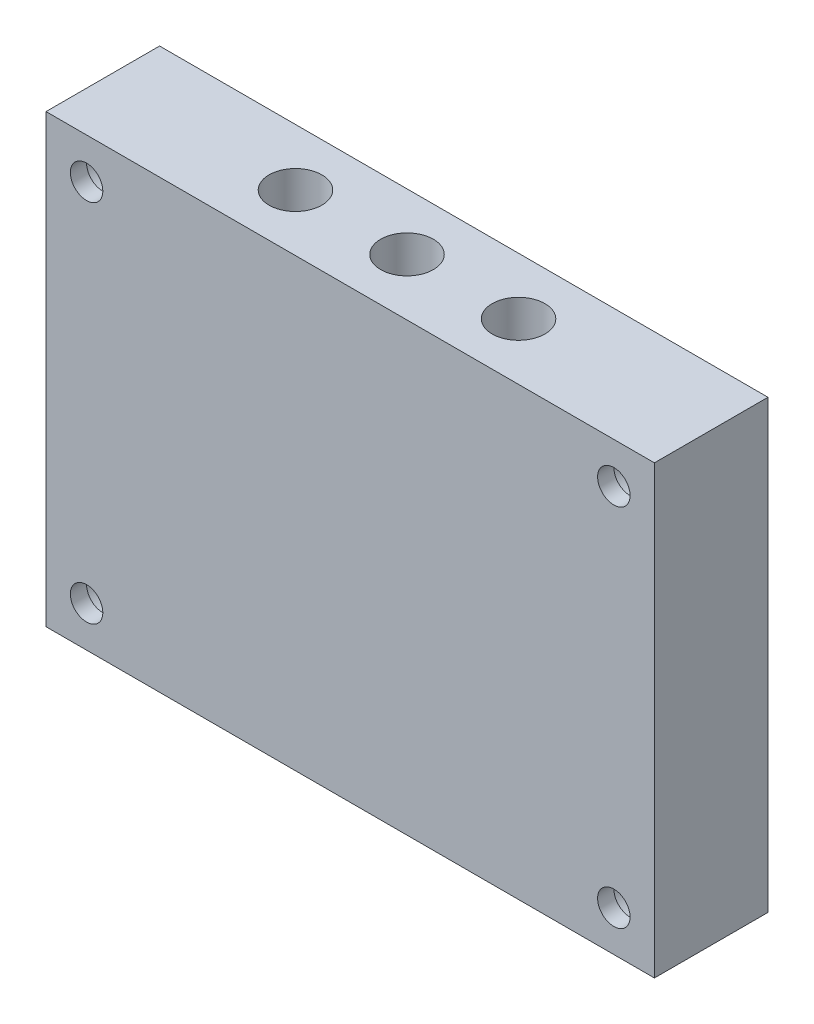
from build123d import *

# Parameters (mm, degrees)
SKETCH2_W               = 75
SKETCH2_H               = 55
SKETCH2_W_2             = 55
SKETCH2_H_2             = 35
BOSS_EXTRUDE1_DEPTH     = 12
SKETCH3_W               = 75
SKETCH3_H               = 55
BOSS_EXTRUDE2_DEPTH     = 2
SKETCH5_R               = 1.32
CUT_EXTRUDE1_DEPTH      = 46
CUT_EXTRUDE1_DEPTH_BACK = 11
SKETCH6_R               = 3.25
CUT_EXTRUDE2_DEPTH      = 8
SKETCH8_R               = 3.25
CUT_EXTRUDE4_DEPTH      = 12
SKETCH9_R               = 2
CUT_EXTRUDE5_DEPTH      = 15


with BuildPart() as part:
    # Sketch2 → Boss-Extrude1 (new body)
    with BuildSketch(Plane.XY):
        with Locations((-37.5, -27.5)):
            Rectangle(SKETCH2_W, SKETCH2_H)
        with Locations((-37.5, -27.5)):
            Rectangle(SKETCH2_W_2, SKETCH2_H_2, mode=Mode.SUBTRACT)
    extrude(amount=BOSS_EXTRUDE1_DEPTH)

    # Sketch3 → Boss-Extrude2 (add)
    with BuildSketch(Plane.XY.offset(12)):
        with Locations((-37.5, -27.5)):
            Rectangle(SKETCH3_W, SKETCH3_H)
    extrude(amount=BOSS_EXTRUDE2_DEPTH)

    # Sketch5 → Cut-Extrude1 (cut, two sides)
    with BuildSketch(Plane(origin=(0, -45, 0), x_dir=(1, 0, 0), z_dir=(0, 1, 0))) as cut_extrude1_sk:
        with Locations((-51.25, -7)):
            Circle(SKETCH5_R)
        with Locations((-23.75, -7)):
            Circle(SKETCH5_R)
        with Locations((-37.5, -7)):
            Circle(SKETCH5_R)
    extrude(amount=CUT_EXTRUDE1_DEPTH, mode=Mode.SUBTRACT)
    extrude(cut_extrude1_sk.sketch, amount=-CUT_EXTRUDE1_DEPTH_BACK, mode=Mode.SUBTRACT)

    # Sketch6 → Cut-Extrude2 (cut)
    with BuildSketch(Plane(origin=(0, 0, 0), x_dir=(1, 0, 0), z_dir=(0, 1, 0))):
        with Locations((-51.25, -7)):
            Circle(SKETCH6_R)
        with Locations((-37.5, -7)):
            Circle(SKETCH6_R)
        with Locations((-23.75, -7)):
            Circle(SKETCH6_R)
    extrude(amount=-CUT_EXTRUDE2_DEPTH, mode=Mode.SUBTRACT)

    # Sketch8 → Cut-Extrude4 (cut)
    with BuildSketch(Plane(origin=(0, 0, 0), x_dir=(-1, 0, 0), z_dir=(0, 0, -1))):
        with Locations((5, -5)):
            Circle(SKETCH8_R)
        with Locations((70, -5)):
            Circle(SKETCH8_R)
        with Locations((70, -50)):
            Circle(SKETCH8_R)
        with Locations((5, -50)):
            Circle(SKETCH8_R)
    extrude(amount=-CUT_EXTRUDE4_DEPTH, mode=Mode.SUBTRACT)

    # Sketch9 → Cut-Extrude5 (cut, through all)
    with BuildSketch(Plane(origin=(0, 0, 0), x_dir=(-1, 0, 0), z_dir=(0, 0, -1))):
        with Locations((5, -5)):
            Circle(SKETCH9_R)
        with Locations((70, -5)):
            Circle(SKETCH9_R)
        with Locations((70, -50)):
            Circle(SKETCH9_R)
        with Locations((5, -50)):
            Circle(SKETCH9_R)
    extrude(amount=-CUT_EXTRUDE5_DEPTH, mode=Mode.SUBTRACT)


solid = part.part
